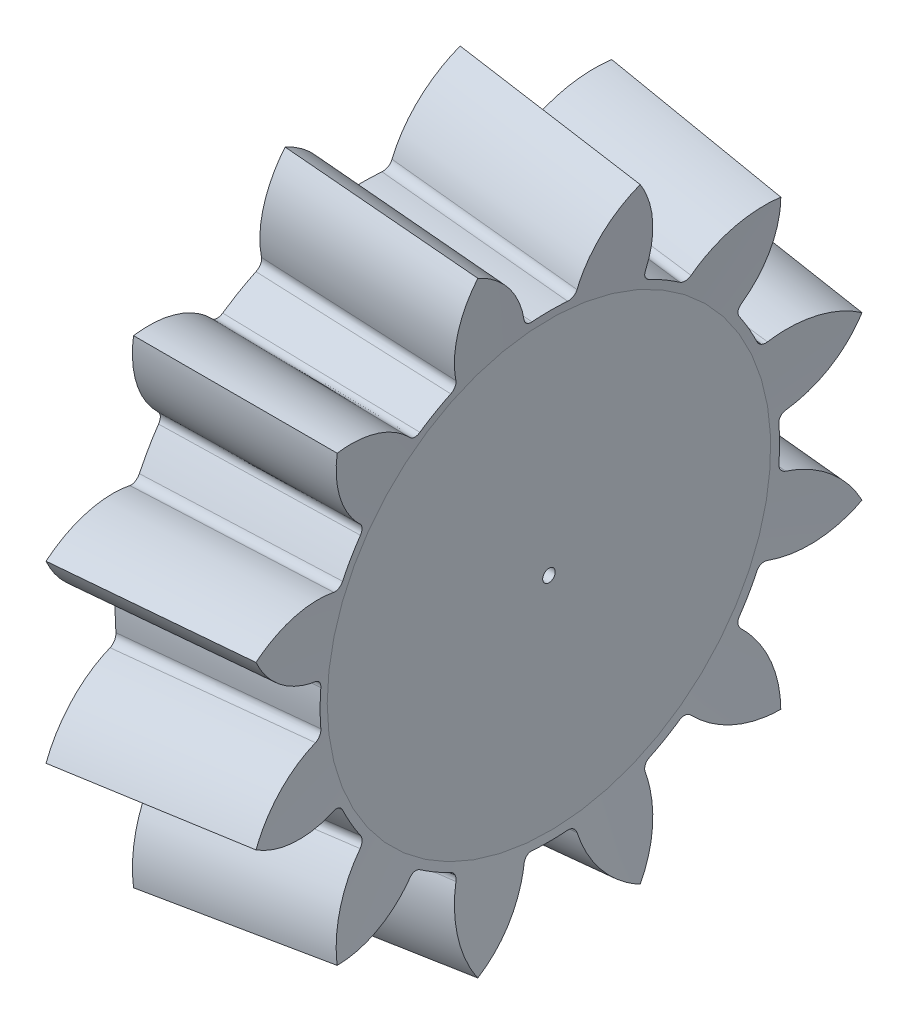
from build123d import *

# Parameters (mm, degrees)
TOOCUTSKE2_R    = 0.0127
TEETHCUTS_COUNT = 12
TEETHCUTS_ANGLE = 330
HUBSKE_R        = 15.26445058
HUB_DEPTH       = 0.0001016
BORSKE_R        = 0.4
BORE_DEPTH      = 165.298474373


with BuildPart() as part:
    # BasProSke → Base-Revolve (revolve)
    with BuildSketch(Plane(origin=(0, 0, 0), x_dir=(1, 0, 0), z_dir=(0, 1, 0))):
        Polygon((0, 0), (0, 15.264450581), (0.77164262, 22.337841254), (12.666655787, 20.722852407), (11.950801648, 14.16085614), (11.950801648, 0), align=None)
    revolve(axis=Axis((-10, 0, 0), (1, 0, 0)))

    # TooCutSke2 → ToothCut section 0
    with BuildSketch(Plane(origin=(163.354371544, -17.820476916, 0), x_dir=(0, 0, 1), z_dir=(-0.994102177, 0.10844751, 0))):
        with Locations((0, 17.926202472)):
            Circle(TOOCUTSKE2_R)
    # TooCutSke → ToothCut section 1
    with BuildSketch(Plane(origin=(0.38582131, 18.801145917, 0), x_dir=(0, 0, -1), z_dir=(-0.994102177, 0.10844751, 0))):
        with BuildLine():
            ThreePointArc((-7.540303337, -2.722654867), (0, -4.00494943), (7.540303337, -2.722654867))
            ThreePointArc((7.540303337, -2.722654867), (3.888620832, -0.893316776), (1.819559236, 2.628081678))
            ThreePointArc((1.819559236, 2.628081678), (1.601685032, 2.950073645), (1.227353765, 3.055069353))
            ThreePointArc((1.227353765, 3.055069353), (0, 3.007322107), (-1.227353765, 3.055069353))
            ThreePointArc((-1.227353765, 3.055069353), (-1.601685032, 2.950073645), (-1.819559236, 2.628081678))
            ThreePointArc((-1.819559236, 2.628081678), (-3.888620832, -0.893316776), (-7.540303337, -2.722654867))
        make_face()
    toothcut = loft(mode=Mode.SUBTRACT)

    # TeethCuts: ToothCut ×12 about axis
    teethcuts_axis = Axis((-10, 0, 0), (1, 0, 0))
    for i in range(1, TEETHCUTS_COUNT):
        add(toothcut.rotate(teethcuts_axis, i * TEETHCUTS_ANGLE / (TEETHCUTS_COUNT - 1)), mode=Mode.SUBTRACT)

    # HubSke → Hub (add)
    with BuildSketch(Plane.ZY):
        Circle(HUBSKE_R)
    extrude(amount=HUB_DEPTH)

    # BorSke → Bore (cut, symmetric)
    with BuildSketch(Plane(origin=(0, 0, 0), x_dir=(0, 0, -1), z_dir=(1, 0, 0))):
        Circle(BORSKE_R)
    extrude(amount=BORE_DEPTH, both=True, mode=Mode.SUBTRACT)


solid = part.part
